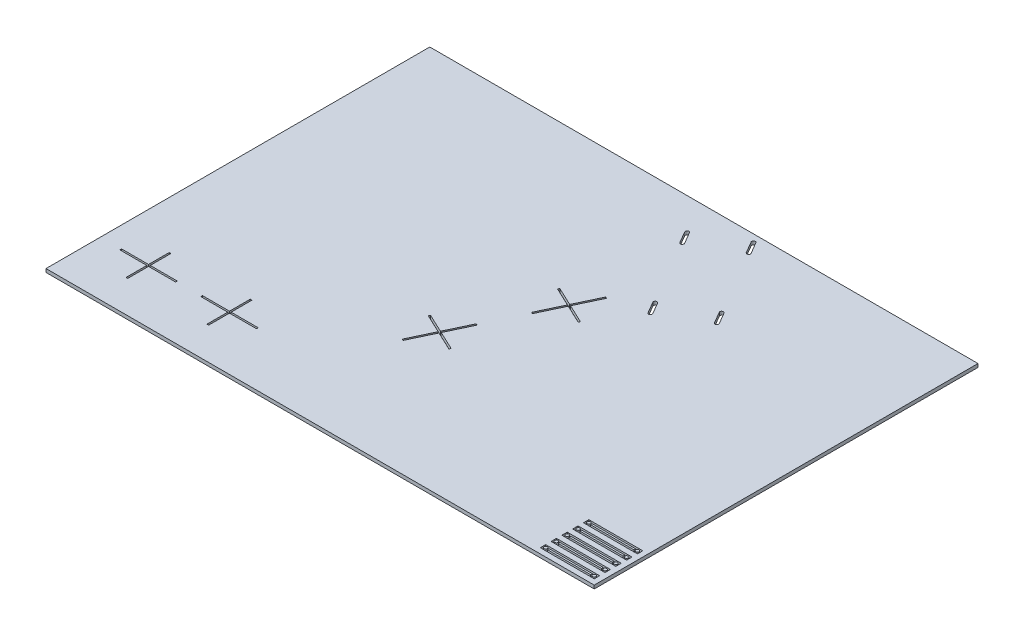
from build123d import *

# Parameters (mm, degrees)
SKETCH1_W           = 1016
SKETCH1_H           = 711.2
BOSS_EXTRUDE1_DEPTH = 6.35
SKETCH2_W           = 3.175
SKETCH2_H           = 80
CUT_EXTRUDE1_DEPTH  = 6.35
SKETCH4_W           = 50
SKETCH4_H           = 3.175
CUT_EXTRUDE2_DEPTH  = 10
SKETCH5_W           = 100
SKETCH5_H           = 10
SKETCH5_R           = 3
SKETCH5_W_2         = 80
SKETCH5_H_2         = 3.175
CUT_EXTRUDE3_DEPTH  = 10


with BuildPart() as part:
    # Sketch1 → Boss-Extrude1 (new body)
    with BuildSketch(Plane(origin=(0, 0, 0), x_dir=(1, 0, 0), z_dir=(0, 1, 0))):
        with Locations((508, -355.6)):
            Rectangle(SKETCH1_W, SKETCH1_H)
    extrude(amount=BOSS_EXTRUDE1_DEPTH)

    # Sketch2 → Cut-Extrude1 (cut)
    with BuildSketch(Plane(origin=(0, 6.35, 0), x_dir=(1, 0, 0), z_dir=(0, 1, 0))):
        Polygon((431.329491407, -429.910471079), (503.676837849, -464.055184621), (502.32171953, -466.926469933), (429.974373088, -432.781756391), align=None)
        with Locations((90, -611.2)):
            Rectangle(SKETCH2_W, SKETCH2_H)
        with Locations((240, -611.2)):
            Rectangle(SKETCH2_W, SKETCH2_H)
        Polygon((508.155096876, -267.128941585), (580.502443318, -301.273655127), (579.147324999, -304.144940439), (506.799978557, -270.000226897), align=None)
        with BuildLine():
            Line((538.629064713, -57.34841943), (551.260028142, -78.92291277))
            ThreePointArc((551.260028142, -78.92291277), (550.097369254, -83.369622149), (545.650659874, -82.206963261))
            Line((545.650659874, -82.206963261), (533.019696445, -60.632469921))
            ThreePointArc((533.019696445, -60.632469921), (534.182355333, -56.185760542), (538.629064713, -57.34841943))
        make_face()
        with BuildLine():
            Line((616.297240736, -11.876951086), (628.928204164, -33.451444426))
            ThreePointArc((628.928204164, -33.451444426), (627.765545276, -37.898153806), (623.318835896, -36.735494917))
            Line((623.318835896, -36.735494917), (610.687872467, -15.161001578))
            ThreePointArc((610.687872467, -15.161001578), (611.850531356, -10.714292198), (616.297240736, -11.876951086))
        make_face()
        with BuildLine():
            Line((712.292562795, -175.843100467), (699.661599366, -154.268607128))
            ThreePointArc((699.661599366, -154.268607128), (695.214889986, -153.105948239), (694.052231097, -157.552657619))
            Line((694.052231097, -157.552657619), (706.683194526, -179.127150959))
            ThreePointArc((706.683194526, -179.127150959), (711.129903906, -180.289809847), (712.292562795, -175.843100467))
        make_face()
        with BuildLine():
            Line((634.624386772, -221.314568811), (621.993423343, -199.740075471))
            ThreePointArc((621.993423343, -199.740075471), (617.546713963, -198.577416583), (616.384055075, -203.024125963))
            Line((616.384055075, -203.024125963), (629.015018504, -224.598619302))
            ThreePointArc((629.015018504, -224.598619302), (633.461727884, -225.761278191), (634.624386772, -221.314568811))
        make_face()
    extrude(amount=-CUT_EXTRUDE1_DEPTH, mode=Mode.SUBTRACT)

    # Sketch4 → Cut-Extrude2 (cut)
    with BuildSketch(Plane(origin=(0, 6.35, 0), x_dir=(1, 0, 0), z_dir=(0, 1, 0))):
        Polygon((467.583688965, -450.531672321), (446.243243002, -495.748763847), (443.37195769, -494.393645529), (464.712403653, -449.176554003), align=None)
        with Locations((63.4125, -611.2)):
            Rectangle(SKETCH4_W, SKETCH4_H)
        with Locations((116.5875, -611.2)):
            Rectangle(SKETCH4_W, SKETCH4_H)
        with Locations((213.4125, -611.2)):
            Rectangle(SKETCH4_W, SKETCH4_H)
        with Locations((266.5875, -611.2)):
            Rectangle(SKETCH4_W, SKETCH4_H)
        Polygon((487.407967936, -401.088177165), (466.067521972, -446.305268691), (468.938807284, -447.660387009), (490.279253247, -402.443295483), align=None)
        Polygon((541.538009122, -286.395024509), (520.197563159, -331.612116035), (523.06884847, -332.967234354), (544.409294434, -287.750142828), align=None)
        Polygon((564.233573404, -238.306647671), (542.893127441, -283.523739197), (545.764412753, -284.878857516), (567.104858716, -239.66176599), align=None)
    extrude(amount=-CUT_EXTRUDE2_DEPTH, mode=Mode.SUBTRACT)

    # Sketch5 → Cut-Extrude3 (cut)
    with BuildSketch(Plane(origin=(0, 6.35, 0), x_dir=(1, 0, 0), z_dir=(0, 1, 0))):
        with Locations((956, -696.2)):
            Rectangle(SKETCH5_W, SKETCH5_H)
        with Locations((911, -696.2)):
            Circle(SKETCH5_R, mode=Mode.SUBTRACT)
        with Locations((1001, -696.2)):
            Circle(SKETCH5_R, mode=Mode.SUBTRACT)
        with Locations((956, -696.2)):
            Rectangle(SKETCH5_W_2, SKETCH5_H_2, mode=Mode.SUBTRACT)
        with Locations((956, -676.2)):
            Rectangle(SKETCH5_W, SKETCH5_H)
        with Locations((911, -676.2)):
            Circle(SKETCH5_R, mode=Mode.SUBTRACT)
        with Locations((1001, -676.2)):
            Circle(SKETCH5_R, mode=Mode.SUBTRACT)
        with Locations((956, -676.2)):
            Rectangle(SKETCH5_W_2, SKETCH5_H_2, mode=Mode.SUBTRACT)
        with Locations((956, -656.2)):
            Rectangle(SKETCH5_W, SKETCH5_H)
        with Locations((911, -656.2)):
            Circle(SKETCH5_R, mode=Mode.SUBTRACT)
        with Locations((1001, -656.2)):
            Circle(SKETCH5_R, mode=Mode.SUBTRACT)
        with Locations((956, -656.2)):
            Rectangle(SKETCH5_W_2, SKETCH5_H_2, mode=Mode.SUBTRACT)
        with Locations((956, -616.2)):
            Rectangle(SKETCH5_W, SKETCH5_H)
        with Locations((911, -616.2)):
            Circle(SKETCH5_R, mode=Mode.SUBTRACT)
        with Locations((1001, -616.2)):
            Circle(SKETCH5_R, mode=Mode.SUBTRACT)
        with Locations((956, -616.2)):
            Rectangle(SKETCH5_W_2, SKETCH5_H_2, mode=Mode.SUBTRACT)
        with Locations((956, -636.2)):
            Rectangle(SKETCH5_W, SKETCH5_H)
        with Locations((911, -636.2)):
            Circle(SKETCH5_R, mode=Mode.SUBTRACT)
        with Locations((1001, -636.2)):
            Circle(SKETCH5_R, mode=Mode.SUBTRACT)
        with Locations((956, -636.2)):
            Rectangle(SKETCH5_W_2, SKETCH5_H_2, mode=Mode.SUBTRACT)
    extrude(amount=-CUT_EXTRUDE3_DEPTH, mode=Mode.SUBTRACT)


solid = part.part
